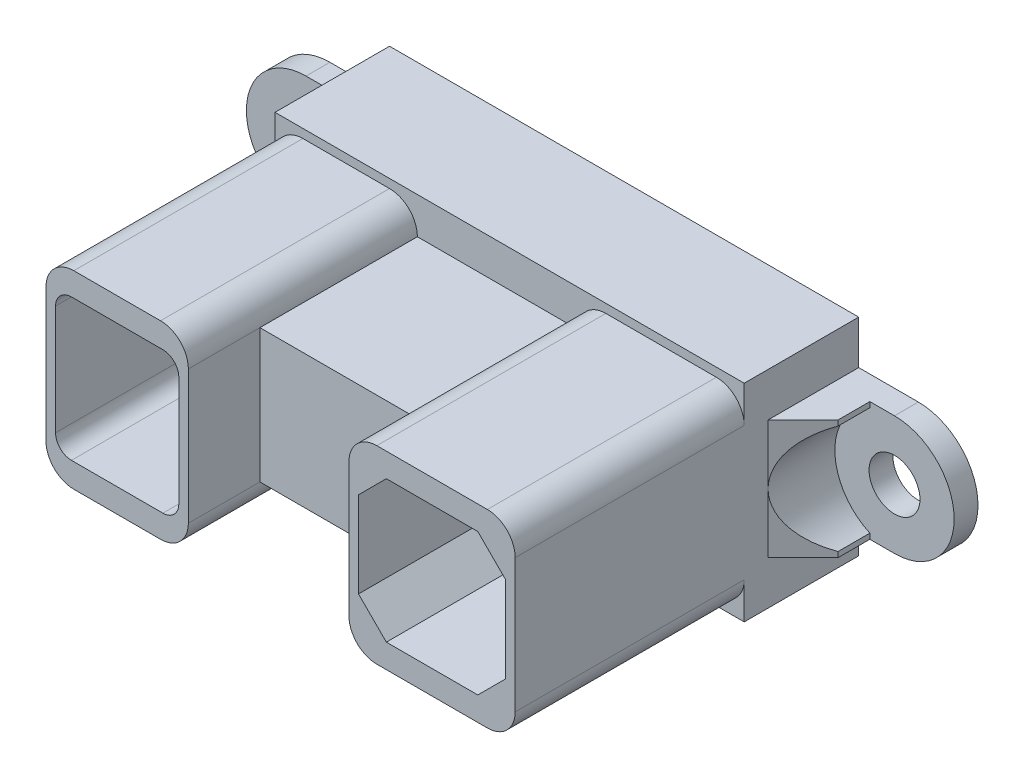
from build123d import *

# Parameters (mm, degrees)
SKETCH1_R           = 1.6
BOSS_EXTRUDE1_DEPTH = 7.2
SKETCH2_R           = 3.75
CUT_EXTRUDE1_DEPTH  = 5.7
CUT_EXTRUDE2_DEPTH  = 7.5
SKETCH5_W           = 7.75
SKETCH5_H           = 8.9
SKETCH5_W_2         = 9.25
BOSS_EXTRUDE2_DEPTH = 14.4
SKETCH6_W           = 10.1
SKETCH6_H           = 8.4
CUT_EXTRUDE3_DEPTH  = 4.5
FILLET1_R           = 1.75
FILLET2_R           = 1
CHAMFER1_SIZE       = 1.75
CUT_EXTRUDE4_DEPTH  = 3.3
CUT_EXTRUDE5_REACH  = 20.3
SKETCH8_W           = 10.1
SKETCH8_H           = 0.75
SKETCH9_W           = 10.1
SKETCH9_H           = 1.2
BOSS_EXTRUDE3_DEPTH = 5.5


with BuildPart() as part:
    # Sketch1 → Boss-Extrude1 (new body)
    with BuildSketch(Plane.XY):
        with BuildLine():
            ThreePointArc((18.5, 3.75), (22.25, 0), (18.5, -3.75))
            Line((18.5, -3.75), (14.75, -3.75))
            Line((14.75, -3.75), (14.75, -6.5))
            Line((14.75, -6.5), (-14.75, -6.5))
            Line((-14.75, -6.5), (-14.75, -3.75))
            Line((-14.75, -3.75), (-18.5, -3.75))
            ThreePointArc((-18.5, -3.75), (-22.25, 0), (-18.5, 3.75))
            Line((-18.5, 3.75), (-14.75, 3.75))
            Line((-14.75, 3.75), (-14.75, 6.5))
            Line((-14.75, 6.5), (14.75, 6.5))
            Line((14.75, 6.5), (14.75, 3.75))
            Line((14.75, 3.75), (18.5, 3.75))
        make_face()
        with Locations((-18.5, 0)):
            Circle(SKETCH1_R, mode=Mode.SUBTRACT)
        with Locations((18.5, 0)):
            Circle(SKETCH1_R, mode=Mode.SUBTRACT)
    extrude(amount=BOSS_EXTRUDE1_DEPTH)

    # Sketch2 → Cut-Extrude1 (cut)
    with BuildSketch(Plane.XY.offset(7.2)):
        with Locations((-18.5, 0)):
            Circle(SKETCH2_R)
        with Locations((18.5, 0)):
            Circle(SKETCH2_R)
    extrude(amount=-CUT_EXTRUDE1_DEPTH, mode=Mode.SUBTRACT)

    # Sketch4 → Cut-Extrude2 (cut)
    with BuildSketch(Plane.XZ.offset(3.75)):
        Polygon((-18.5, 1.5), (-16.95, 1.5), (-16.95, 3.5), (-14.75, 5.7), (-14.75, 7.2), (-18.5, 7.2), align=None)
        Polygon((18.5, 1.5), (16.95, 1.5), (16.95, 3.5), (14.75, 5.7), (14.75, 7.2), (18.5, 7.2), align=None)
    extrude(amount=-CUT_EXTRUDE2_DEPTH, mode=Mode.SUBTRACT)

    # Sketch5 → Boss-Extrude2 (add)
    with BuildSketch(Plane.XY.offset(7.2)):
        Polygon((-5.8, -5.95), (-14.75, -5.95), (-14.75, 5.95), (-5.8, 5.95), (-5.8, 4.2), (0, 4.2), (4.3, 4.2), (4.3, 5.95), (14.75, 5.95), (14.75, -5.95), (4.3, -5.95), (4.3, -4.2), (0, -4.2), (-5.8, -4.2), align=None)
        with Locations((-10.275, 0)):
            Rectangle(SKETCH5_W, SKETCH5_H, mode=Mode.SUBTRACT)
        with Locations((9.525, 0)):
            Rectangle(SKETCH5_W_2, SKETCH5_H, mode=Mode.SUBTRACT)
    extrude(amount=BOSS_EXTRUDE2_DEPTH)

    # Sketch6 → Cut-Extrude3 (cut)
    with BuildSketch(Plane.XY.offset(21.6)):
        with Locations((-0.75, 0)):
            Rectangle(SKETCH6_W, SKETCH6_H)
    extrude(amount=-CUT_EXTRUDE3_DEPTH, mode=Mode.SUBTRACT)

    # Fillet1
    fillet1_edges = [part.edges().sort_by_distance(p)[0] for p in [
        (4.3, 5.95, 14.4),
        (14.75, 5.95, 14.4),
        (14.75, -5.95, 14.4),
        (4.3, -5.95, 14.4),
        (-5.8, 5.95, 14.4),
        (-14.75, 5.95, 14.4),
        (-14.75, -5.95, 14.4),
        (-5.8, -5.95, 14.4),
    ]]
    fillet(fillet1_edges, radius=FILLET1_R)

    # Fillet2
    fillet2_edges = [part.edges().sort_by_distance(p)[0] for p in [
        (-6.4, 4.45, 14.4),
        (-14.15, 4.45, 14.4),
        (-14.15, -4.45, 14.4),
        (-6.4, -4.45, 14.4),
    ]]
    fillet(fillet2_edges, radius=FILLET2_R)

    # Chamfer1
    chamfer1_edges = [part.edges().sort_by_distance(p)[0] for p in [
        (14.15, 4.45, 14.4),
        (4.9, 4.45, 14.4),
        (4.9, -4.45, 14.4),
        (14.15, -4.45, 14.4),
    ]]
    chamfer(chamfer1_edges, length=CHAMFER1_SIZE)

    # Sketch7 → Cut-Extrude4 (cut)
    with BuildSketch(Plane(origin=(0, 0, 0), x_dir=(-1, 0, 0), z_dir=(0, 0, -1))):
        Polygon((14, -5.75), (14, 5.75), (-14, 5.75), (-14, -5.75), (-5.05, -5.75), (-5.05, -6.5), (5.05, -6.5), (5.05, -5.75), align=None)
    extrude(amount=-CUT_EXTRUDE4_DEPTH, mode=Mode.SUBTRACT)

    # Sketch8 → Cut-Extrude5 (cut, up to next)
    with BuildSketch(Plane(origin=(0, 0, 3.3), x_dir=(-1, 0, 0), z_dir=(0, 0, -1)), mode=Mode.PRIVATE) as cut_extrude5_sk1:
        with Locations((0, -6.125)):
            Rectangle(SKETCH8_W, SKETCH8_H)
    cut_extrude5_tool1 = extrude(cut_extrude5_sk1.sketch, amount=-CUT_EXTRUDE5_REACH, mode=Mode.PRIVATE) & part.part
    add(cut_extrude5_tool1.solids().sort_by_distance((0, -6.125, 3.3))[0], mode=Mode.SUBTRACT)

    # Sketch9 → Boss-Extrude3 (add)
    with BuildSketch(Plane.XZ.offset(5.75)):
        with Locations((0, 3.9)):
            Rectangle(SKETCH9_W, SKETCH9_H)
    extrude(amount=BOSS_EXTRUDE3_DEPTH)


solid = part.part
